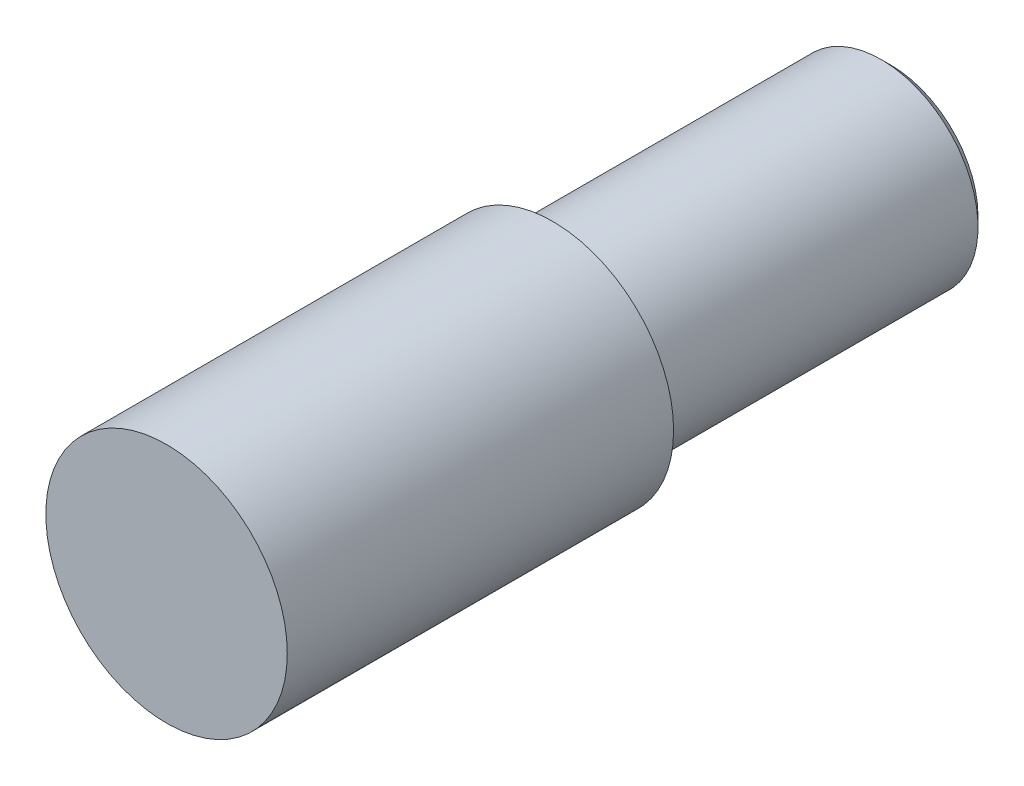
from build123d import *

# Parameters (mm, degrees)
SKETCH1_R           = 12.5
BOSS_EXTRUDE1_DEPTH = 40
SKETCH2_R           = 10.02
BOSS_EXTRUDE2_DEPTH = 35
CHAMFER1_SIZE       = 1


with BuildPart() as part:
    # Sketch1 → Boss-Extrude1 (new body)
    with BuildSketch(Plane.XY):
        Circle(SKETCH1_R)
    extrude(amount=-BOSS_EXTRUDE1_DEPTH)

    # Sketch2 → Boss-Extrude2 (add)
    with BuildSketch(Plane(origin=(0, 0, -40), x_dir=(-1, 0, 0), z_dir=(0, 0, -1))):
        Circle(SKETCH2_R)
    extrude(amount=BOSS_EXTRUDE2_DEPTH)

    # Chamfer1
    chamfer1_edges = [part.edges().sort_by_distance(p)[0] for p in [
        (10.02, 0, -75),
    ]]
    chamfer(chamfer1_edges, length=CHAMFER1_SIZE)


solid = part.part
